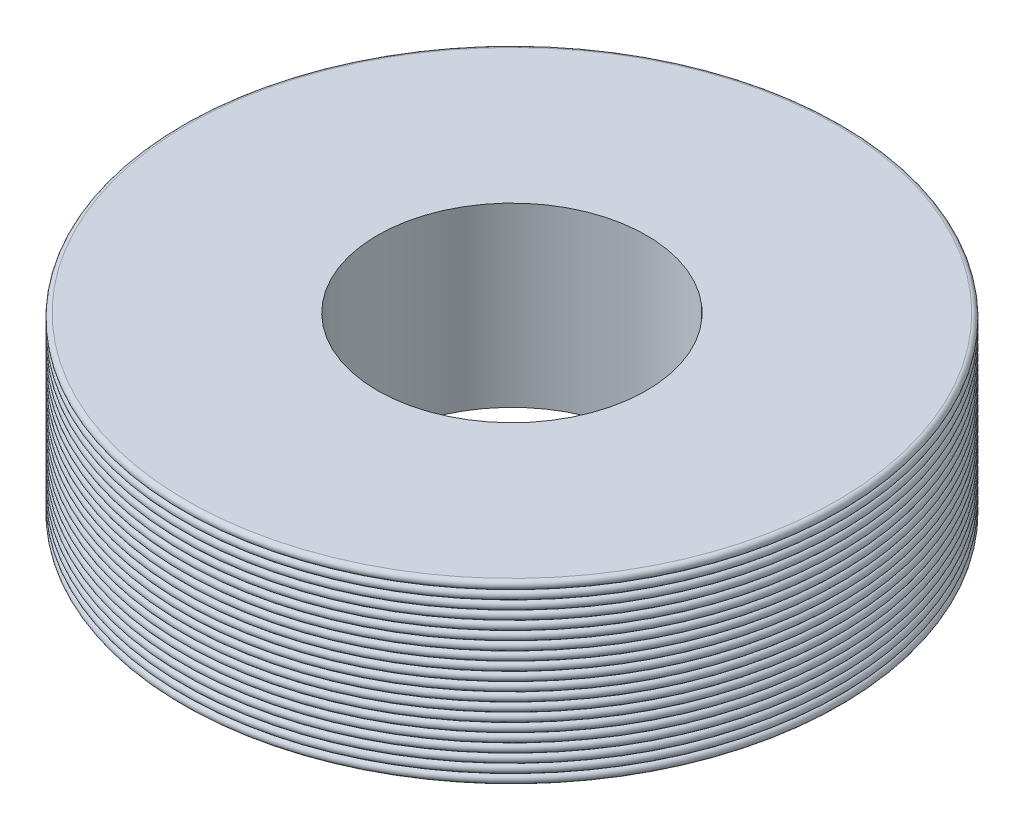
from build123d import *
from build123d.topology import SkipClean

# Parameters (mm, degrees)
SKETCH1_R           = 98
SKETCH1_R_2         = 40
BOSS_EXTRUDE1_DEPTH = 52.6


with BuildPart() as part:
    # Sketch1 → Boss-Extrude1 (new body)
    with BuildSketch(Plane(origin=(0, 0, 0), x_dir=(1, 0, 0), z_dir=(0, 1, 0))):
        with Locations(Location((0, 0, 0), (0, 0, 270))):
            Circle(SKETCH1_R)
        with Locations(Location((0, 0, 0), (0, 0, 270))):
            Circle(SKETCH1_R_2, mode=Mode.SUBTRACT)
    extrude(amount=BOSS_EXTRUDE1_DEPTH)

    # Sketch2 → Cut-Revolve1 (revolve, cut)
    with SkipClean():  # the faces are left unmerged after this step: merging them gives an invalid solid
        with BuildSketch(Plane.XY, mode=Mode.PRIVATE) as cut_revolve1_sk:
            with BuildLine():
                Line((-101.547865046, 52.6), (-101.547865046, 0))
                Line((-101.547865046, 0), (-96.685, 0))
                ThreePointArc((-96.685, 0), (-98, 1.315), (-96.685, 2.63))
                ThreePointArc((-96.685, 2.63), (-98, 3.945), (-96.685, 5.26))
                ThreePointArc((-96.685, 5.26), (-98, 6.575), (-96.685, 7.89))
                ThreePointArc((-96.685, 7.89), (-98, 9.205), (-96.685, 10.52))
                ThreePointArc((-96.685, 10.52), (-98, 11.835), (-96.685, 13.15))
                ThreePointArc((-96.685, 13.15), (-98, 14.465), (-96.685, 15.78))
                ThreePointArc((-96.685, 15.78), (-98, 17.095), (-96.685, 18.41))
                ThreePointArc((-96.685, 18.41), (-98, 19.725), (-96.685, 21.04))
                ThreePointArc((-96.685, 21.04), (-98, 22.355), (-96.685, 23.67))
                ThreePointArc((-96.685, 23.67), (-98, 24.985), (-96.685, 26.3))
                ThreePointArc((-96.685, 26.3), (-98, 27.615), (-96.685, 28.93))
                ThreePointArc((-96.685, 28.93), (-98, 30.245), (-96.685, 31.56))
                ThreePointArc((-96.685, 31.56), (-98, 32.875), (-96.685, 34.19))
                ThreePointArc((-96.685, 34.19), (-98, 35.505), (-96.685, 36.82))
                ThreePointArc((-96.685, 36.82), (-98, 38.135), (-96.685, 39.45))
                ThreePointArc((-96.685, 39.45), (-98, 40.765), (-96.685, 42.08))
                ThreePointArc((-96.685, 42.08), (-98, 43.395), (-96.685, 44.71))
                ThreePointArc((-96.685, 44.71), (-98, 46.025), (-96.685, 47.34))
                ThreePointArc((-96.685, 47.34), (-98, 48.655), (-96.685, 49.97))
                ThreePointArc((-96.685, 49.97), (-98, 51.285), (-96.685, 52.6))
                Line((-96.685, 52.6), (-101.547865046, 52.6))
            make_face()
        revolve(cut_revolve1_sk.sketch.rotate(Axis((0, 0, 0), (0, 1, 0)), 270), axis=Axis((0, 0, 0), (0, 1, 0)), mode=Mode.SUBTRACT)


solid = part.part
